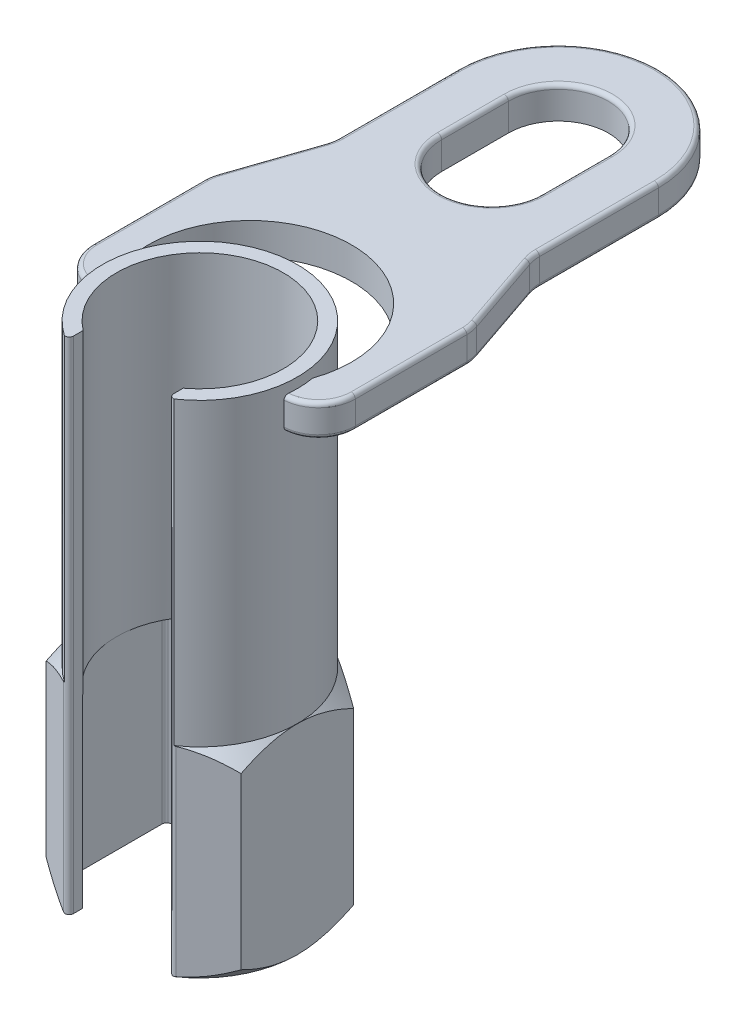
from build123d import *
from build123d.topology import SkipClean

# Parameters (mm, degrees)
EXTRUDE1_DEPTH     = 24
EXTRUDE2_DEPTH     = 36
SKETCH8_OUTSIDE_W  = 161.094
SKETCH8_OUTSIDE_H  = 161.248
SKETCH8_OUTSIDE_R  = 11.691342951
CUT_EXTRUDE4_DEPTH = 61
CUT_EXTRUDE4_DRAFT = -45
SKETCH19_OUTSIDE_W = 89.094
SKETCH19_OUTSIDE_H = 89.248
SKETCH19_OUTSIDE_R = 11.691242951
CUT_EXTRUDE6_DEPTH = 25
CUT_EXTRUDE6_DRAFT = -45
CUT_EXTRUDE9_DEPTH = 22.19124
FILLET1_R          = 0.5
EXTRUDE7_DEPTH     = 3.8
CUT_EXTRUDE8_REACH = 60.8
FILLET4_R          = 0.5


with BuildPart() as part:
    # Sketch1 → Extrude1 (new body)
    with BuildSketch(Plane(origin=(0, 0, 0), x_dir=(1, 0, 0), z_dir=(0, 1, 0))):
        with BuildLine():
            Line((-6, -8), (-6, -10.035898385))
            Line((-6, -10.035898385), (-11.691342951, -6.75))
            Line((-11.691342951, -6.75), (-11.691342951, 6.75))
            Line((-11.691342951, 6.75), (0, 13.5))
            Line((0, 13.5), (11.691342951, 6.75))
            Line((11.691342951, 6.75), (11.691342951, -6.75))
            Line((11.691342951, -6.75), (6, -10.035898385))
            Line((6, -10.035898385), (6, -8))
            ThreePointArc((6, -8), (0, 10), (-6, -8))
        make_face()
    extrude(amount=EXTRUDE1_DEPTH)

    # Sketch3 → Extrude2 (add)
    with BuildSketch(Plane(origin=(0, 24, 0), x_dir=(-1, 0, 0), z_dir=(0, 1, 0))):
        with BuildLine():
            Line((-6, 10.034199606), (-6, 8))
            ThreePointArc((-6, 8), (0, -10), (6, 8))
            Line((6, 8), (6, 10.034199606))
            ThreePointArc((6, 10.034199606), (0, -11.691242951), (-6, 10.034199606))
        make_face()
    extrude(amount=EXTRUDE2_DEPTH)


with BuildPart() as cut_extrude4_tool:
    # Sketch8 outside → Cut-Extrude4 (with draft: the straight prism first)
    with BuildSketch(Plane.XZ):
        with Locations((0, -1.732)):
            Rectangle(SKETCH8_OUTSIDE_W, SKETCH8_OUTSIDE_H)
        Circle(SKETCH8_OUTSIDE_R, mode=Mode.SUBTRACT)
    extrude(amount=-CUT_EXTRUDE4_DEPTH)
    # Cut-Extrude4: the draft: its side faces are tilted about the plane it starts from
    cut_extrude4_sides = [cut_extrude4_tool.faces().sort_by_distance(p)[0] for p in [
        (0, 30.5, -82.356),
        (80.547, 30.5, -1.732),
        (0, 30.5, 78.892),
        (-80.547, 30.5, -1.732),
        (-11.691342951, 30.5, 0),
    ]]
    draft(cut_extrude4_sides, Plane.XZ, CUT_EXTRUDE4_DRAFT)


with BuildPart() as part_1:
    add(part.part)

    # Cut-Extrude4: cut by cut_extrude4_tool
    add(cut_extrude4_tool.part, mode=Mode.SUBTRACT)


with BuildPart() as cut_extrude6_tool:
    # Sketch19 outside → Cut-Extrude6 (with draft: the straight prism first)
    with BuildSketch(Plane(origin=(0, 24, 0), x_dir=(-1, 0, 0), z_dir=(0, 1, 0))):
        with Locations((0, -1.732)):
            Rectangle(SKETCH19_OUTSIDE_W, SKETCH19_OUTSIDE_H)
        Circle(SKETCH19_OUTSIDE_R, mode=Mode.SUBTRACT)
    extrude(amount=-CUT_EXTRUDE6_DEPTH)
    # Cut-Extrude6: the draft: its side faces are tilted about the plane it starts from
    cut_extrude6_sides = [cut_extrude6_tool.faces().sort_by_distance(p)[0] for p in [
        (0, 11.5, -46.356),
        (-44.547, 11.5, -1.732),
        (0, 11.5, 42.892),
        (44.547, 11.5, -1.732),
        (11.691242951, 11.5, 0),
    ]]
    draft(cut_extrude6_sides, Plane(origin=(0, 24, 0), x_dir=(-1, 0, 0), z_dir=(0, 1, 0)), CUT_EXTRUDE6_DRAFT)


with BuildPart() as part_2:
    add(part_1.part)

    # Cut-Extrude6: cut by cut_extrude6_tool
    add(cut_extrude6_tool.part, mode=Mode.SUBTRACT)

    # Sketch26 → Cut-Extrude9 (cut)
    with BuildSketch(Plane.XZ):
        Polygon((-10, -5.773502692), (0, -11.547005384), (10, -5.773502692), (10, 5.773502692), (0, 11.547005384), (-10, 5.773502692), align=None)
    extrude(amount=-CUT_EXTRUDE9_DEPTH, mode=Mode.SUBTRACT)

    # Fillet1
    fillet1_edges = [part_2.edges().sort_by_distance(p)[0] for p in [
        (-10, 11.09562, -5.773502692),
        (-10, 11.09562, 5.773502692),
        (10, 11.09562, 5.773502692),
        (10, 11.09562, -5.773502692),
        (-6, 11.99995, 10.035898385),
        (6, 11.99995, 10.035898385),
        (0, 11.09562, -11.547005384),
    ]]
    fillet(fillet1_edges, radius=FILLET1_R)

    # Sketch16 → Extrude7 (add)
    with BuildSketch(Plane(origin=(0, 55, 0), x_dir=(-1, 0, 0), z_dir=(0, 1, 0))):
        with BuildLine():
            Line((-12, -43), (-12, -28.729390111))
            ThreePointArc((-12, -28.729390111), (-12.059237553, -28.009819838), (-12.235355172, -27.309624829))
            Line((-12.235355172, -27.309624829), (-15.514644828, -17.690375171))
            ThreePointArc((-15.514644828, -17.690375171), (-15.690762447, -16.990180162), (-15.75, -16.270609889))
            Line((-15.75, -16.270609889), (-15.75, -2.89319498))
            ThreePointArc((-15.75, -2.89319498), (-14.546585544, 0.130352747), (-11.594617792, 1.5))
            ThreePointArc((-11.594617792, 1.5), (0, -11.691242951), (11.594617792, 1.5))
            ThreePointArc((11.594617792, 1.5), (14.546585544, 0.130352747), (15.75, -2.89319498))
            Line((15.75, -2.89319498), (15.75, -16.270609889))
            ThreePointArc((15.75, -16.270609889), (15.690762447, -16.990180162), (15.514644828, -17.690375171))
            Line((15.514644828, -17.690375171), (12.235355172, -27.309624829))
            ThreePointArc((12.235355172, -27.309624829), (12.059237553, -28.009819838), (12, -28.729390111))
            Line((12, -28.729390111), (12, -43))
            ThreePointArc((12, -43), (0, -55), (-12, -43))
        make_face()
    extrude(amount=EXTRUDE7_DEPTH)

    # Sketch25 → Cut-Extrude8 (cut, up to next)
    with BuildSketch(Plane.XZ.offset(-58.8), mode=Mode.PRIVATE) as cut_extrude8_sk1:
        with BuildLine():
            Line((-6, -43), (-6, -35))
            ThreePointArc((-6, -35), (0, -29), (6, -35))
            Line((6, -35), (6, -43))
            ThreePointArc((6, -43), (0, -49), (-6, -43))
        make_face()
    cut_extrude8_tool1 = extrude(cut_extrude8_sk1.sketch, amount=CUT_EXTRUDE8_REACH, mode=Mode.PRIVATE) & part_2.part
    add(cut_extrude8_tool1.solids().sort_by_distance((0, 58.8, -39))[0], mode=Mode.SUBTRACT)
    # Sketch25 → Cut-Extrude8 (cut, up to next)
    with BuildSketch(Plane.XZ.offset(-58.8), mode=Mode.PRIVATE) as cut_extrude8_sk2:
        with BuildLine():
            ThreePointArc((11.518904537, -2), (0, -11.691242951), (-11.518904537, -2))
            ThreePointArc((-11.518904537, -2), (0, -18.193652518), (11.518904537, -2))
        make_face()
    cut_extrude8_tool2 = extrude(cut_extrude8_sk2.sketch, amount=CUT_EXTRUDE8_REACH, mode=Mode.PRIVATE) & part_2.part
    add(cut_extrude8_tool2.solids().sort_by_distance((0, 58.8, -12.2611))[0], mode=Mode.SUBTRACT)

    # Fillet4
    fillet4_edges = [part_2.edges().sort_by_distance(p)[0] for p in [
        (-14.546585544, 55, 0.130352747),
        (14.546585544, 55, 0.130352747),
        (15.75, 55, -9.581902435),
        (15.690762447, 55, -16.990180162),
        (13.875, 55, -22.5),
        (12.059237553, 55, -28.009819838),
        (12, 55, -35.864695056),
        (0, 55, -55),
        (-12, 55, -35.864695056),
        (-12.059237553, 55, -28.009819838),
        (-13.875, 55, -22.5),
        (-15.690762447, 55, -16.990180162),
        (-15.75, 55, -9.581902435),
        (-14.546585544, 58.8, 0.130352747),
        (14.546585544, 58.8, 0.130352747),
        (15.75, 58.8, -9.581902435),
        (15.690762447, 58.8, -16.990180162),
        (13.875, 58.8, -22.5),
        (12.059237553, 58.8, -28.009819838),
        (12, 58.8, -35.864695056),
        (0, 58.8, -55),
        (-12, 58.8, -35.864695056),
        (-12.059237553, 58.8, -28.009819838),
        (-13.875, 58.8, -22.5),
        (-15.690762447, 58.8, -16.990180162),
        (-15.75, 58.8, -9.581902435),
        (0, 58.8, -49),
        (6, 58.8, -39),
        (0, 58.8, -29),
        (-6, 58.8, -39),
    ]]
    fillet(fillet4_edges, radius=FILLET4_R)


solid = part_2.part
